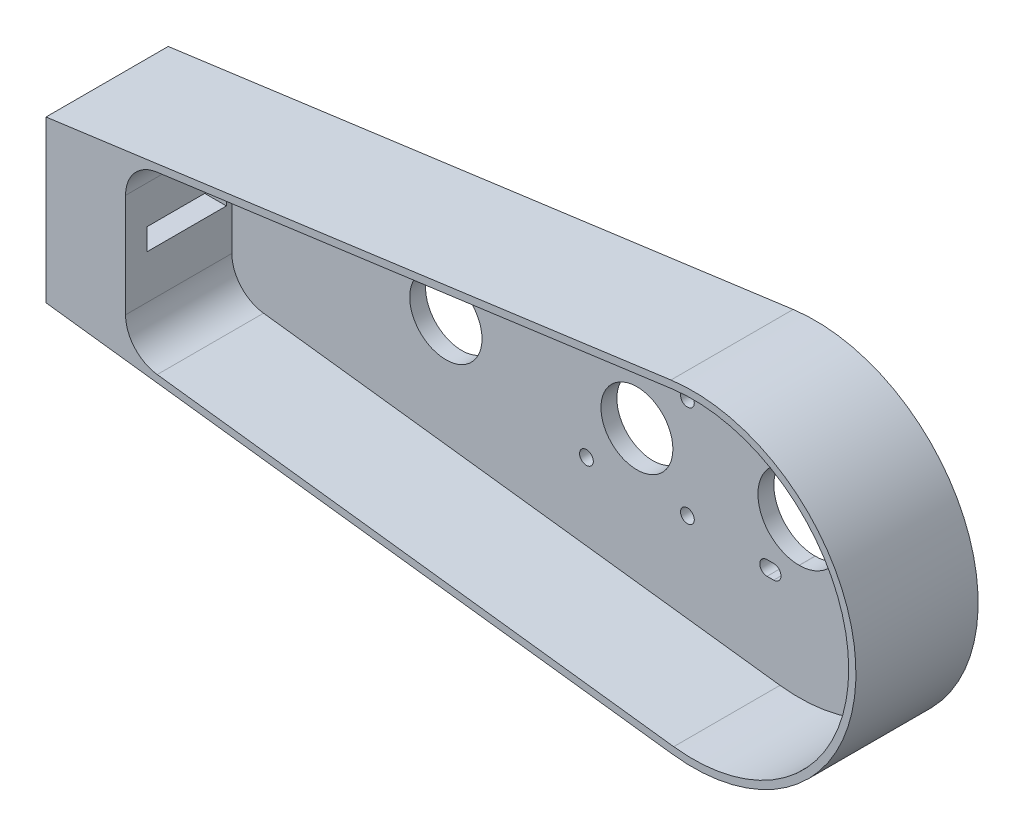
from build123d import *

# Parameters (mm, degrees)
ESBO_O1_R                  = 9.95
ESBO_O1_R_2                = 1.9
ESBO_O1_R_3                = 10
ESBO_O1_R_4                = 2.9
RESSALTO_EXTRUS_O1_DEPTH   = 30.8
ESBO_O1_3_R                = 9.95
ESBO_O1_3_R_2              = 1.9
ESBO_O1_3_R_3              = 10
ESBO_O1_3_R_4              = 2.9
RESSALTO_EXTRUS_O2_DEPTH   = 3
RESSALTO_EXTRUS_O4_DEPTH   = 33.8
CORTE_EXTRUS_O1_DEPTH      = 29.4
ESBO_O1_4_R                = 9.95
ESBO_O1_4_R_2              = 1.9
ESBO_O1_4_R_3              = 10
ESBO_O1_4_R_4              = 2.9
CORTE_EXTRUS_O2_DEPTH      = 31.8
CORTE_EXTRUS_O2_DEPTH_BACK = 4
RESSALTO_EXTRUS_O5_DEPTH   = 30.8
FILETE1_R                  = 10
CORTE_EXTRUS_O3_REACH      = 226.029
ESBO_O5_W                  = 22
ESBO_O5_H                  = 6


with BuildPart() as part:
    # Esboço1 → Ressalto-extrusão1 (new body)
    with BuildSketch(Plane.XY):
        with BuildLine():
            Line((-176.929134073, 19.50886441), (-176.929134073, -21.49113559))
            Line((-176.929134073, -21.49113559), (-5.303716409, -42.772427944))
            ThreePointArc((-5.303716409, -42.772427944), (43.09930295, 0.245122927), (-5.789885285, 42.709334207))
            Line((-5.789885285, 42.709334207), (-176.929134073, 19.50886441))
        make_face()
        with Locations((-44.879134073, -0.99113559)):
            Circle(ESBO_O1_R, mode=Mode.SUBTRACT)
        with Locations((-58.844493002, 12.974223338)):
            Circle(ESBO_O1_R_2, mode=Mode.SUBTRACT)
        with Locations((-97.729134073, -0.99113559)):
            Circle(ESBO_O1_R_3, mode=Mode.SUBTRACT)
        with Locations((-58.844493002, -14.956494518)):
            Circle(ESBO_O1_R_2, mode=Mode.SUBTRACT)
        with Locations((4, 24)):
            Circle(ESBO_O1_R_4, mode=Mode.SUBTRACT)
        with BuildLine():
            Line((22.160394843, 16.45886441), (24.010394843, 16.45886441))
            ThreePointArc((24.010394843, 16.45886441), (26.010394843, 14.45886441), (24.010394843, 12.45886441))
            Line((24.010394843, 12.45886441), (22.160394843, 12.45886441))
            ThreePointArc((22.160394843, 12.45886441), (20.160394843, 14.45886441), (22.160394843, 16.45886441))
        make_face(mode=Mode.SUBTRACT)
        with Locations((-30.913775145, -14.956494518)):
            Circle(ESBO_O1_R_2, mode=Mode.SUBTRACT)
        with BuildLine():
            Line((-7.039605157, -18.44113559), (-8.889605157, -18.44113559))
            ThreePointArc((-8.889605157, -18.44113559), (-10.889605157, -16.44113559), (-8.889605157, -14.44113559))
            Line((-8.889605157, -14.44113559), (-7.039605157, -14.44113559))
            ThreePointArc((-7.039605157, -14.44113559), (-5.039605157, -16.44113559), (-7.039605157, -18.44113559))
        make_face(mode=Mode.SUBTRACT)
        with BuildLine():
            Line((24.010394843, -18.44113559), (22.160394843, -18.44113559))
            ThreePointArc((22.160394843, -18.44113559), (20.160394843, -16.44113559), (22.160394843, -14.44113559))
            Line((22.160394843, -14.44113559), (24.010394843, -14.44113559))
            ThreePointArc((24.010394843, -14.44113559), (26.010394843, -16.44113559), (24.010394843, -18.44113559))
        make_face(mode=Mode.SUBTRACT)
        with Locations((-30.913775145, 12.974223338)):
            Circle(ESBO_O1_R_2, mode=Mode.SUBTRACT)
        with BuildLine():
            ThreePointArc((-0.025, -11.375), (-11.4, 0), (-0.025, 11.375))
            Line((-0.025, 11.375), (0.025, 11.375))
            ThreePointArc((0.025, 11.375), (11.4, 0), (0.025, -11.375))
            Line((0.025, -11.375), (-0.025, -11.375))
        make_face(mode=Mode.SUBTRACT)
        with BuildLine():
            ThreePointArc((-8.889605157, 12.45886441), (-10.889605157, 14.45886441), (-8.889605157, 16.45886441))
            Line((-8.889605157, 16.45886441), (-7.039605157, 16.45886441))
            ThreePointArc((-7.039605157, 16.45886441), (-5.039605157, 14.45886441), (-7.039605157, 12.45886441))
            Line((-7.039605157, 12.45886441), (-8.889605157, 12.45886441))
        make_face(mode=Mode.SUBTRACT)
    extrude(amount=RESSALTO_EXTRUS_O1_DEPTH)

    # Esboço1<3> → Ressalto-extrusão2 (add)
    with BuildSketch(Plane.XY):
        with BuildLine():
            Line((-176.929134073, 19.50886441), (-176.929134073, -21.49113559))
            Line((-176.929134073, -21.49113559), (-5.303716409, -42.772427944))
            ThreePointArc((-5.303716409, -42.772427944), (43.09930295, 0.245122927), (-5.789885285, 42.709334207))
            Line((-5.789885285, 42.709334207), (-176.929134073, 19.50886441))
        make_face()
        with Locations((-44.879134073, -0.99113559)):
            Circle(ESBO_O1_3_R, mode=Mode.SUBTRACT)
        with Locations((-58.844493002, 12.974223338)):
            Circle(ESBO_O1_3_R_2, mode=Mode.SUBTRACT)
        with Locations((-97.729134073, -0.99113559)):
            Circle(ESBO_O1_3_R_3, mode=Mode.SUBTRACT)
        with Locations((-58.844493002, -14.956494518)):
            Circle(ESBO_O1_3_R_2, mode=Mode.SUBTRACT)
        with Locations((4, 24)):
            Circle(ESBO_O1_3_R_4, mode=Mode.SUBTRACT)
        with BuildLine():
            Line((22.160394843, 16.45886441), (24.010394843, 16.45886441))
            ThreePointArc((24.010394843, 16.45886441), (26.010394843, 14.45886441), (24.010394843, 12.45886441))
            Line((24.010394843, 12.45886441), (22.160394843, 12.45886441))
            ThreePointArc((22.160394843, 12.45886441), (20.160394843, 14.45886441), (22.160394843, 16.45886441))
        make_face(mode=Mode.SUBTRACT)
        with Locations((-30.913775145, -14.956494518)):
            Circle(ESBO_O1_3_R_2, mode=Mode.SUBTRACT)
        with BuildLine():
            Line((-7.039605157, -18.44113559), (-8.889605157, -18.44113559))
            ThreePointArc((-8.889605157, -18.44113559), (-10.889605157, -16.44113559), (-8.889605157, -14.44113559))
            Line((-8.889605157, -14.44113559), (-7.039605157, -14.44113559))
            ThreePointArc((-7.039605157, -14.44113559), (-5.039605157, -16.44113559), (-7.039605157, -18.44113559))
        make_face(mode=Mode.SUBTRACT)
        with BuildLine():
            Line((24.010394843, -18.44113559), (22.160394843, -18.44113559))
            ThreePointArc((22.160394843, -18.44113559), (20.160394843, -16.44113559), (22.160394843, -14.44113559))
            Line((22.160394843, -14.44113559), (24.010394843, -14.44113559))
            ThreePointArc((24.010394843, -14.44113559), (26.010394843, -16.44113559), (24.010394843, -18.44113559))
        make_face(mode=Mode.SUBTRACT)
        with Locations((-30.913775145, 12.974223338)):
            Circle(ESBO_O1_3_R_2, mode=Mode.SUBTRACT)
        with BuildLine():
            ThreePointArc((-0.025, -11.375), (-11.4, 0), (-0.025, 11.375))
            Line((-0.025, 11.375), (0.025, 11.375))
            ThreePointArc((0.025, 11.375), (11.4, 0), (0.025, -11.375))
            Line((0.025, -11.375), (-0.025, -11.375))
        make_face(mode=Mode.SUBTRACT)
        with BuildLine():
            ThreePointArc((-8.889605157, 12.45886441), (-10.889605157, 14.45886441), (-8.889605157, 16.45886441))
            Line((-8.889605157, 16.45886441), (-7.039605157, 16.45886441))
            ThreePointArc((-7.039605157, 16.45886441), (-5.039605157, 14.45886441), (-7.039605157, 12.45886441))
            Line((-7.039605157, 12.45886441), (-8.889605157, 12.45886441))
        make_face(mode=Mode.SUBTRACT)
    extrude(amount=-RESSALTO_EXTRUS_O2_DEPTH)

    # Esboço4 → Ressalto-extrusão4 (add, through all)
    with BuildSketch(Plane(origin=(0, 0, -3), x_dir=(-1, 0, 0), z_dir=(0, 0, -1))):
        with BuildLine():
            Line((5.549828539, -44.757227385), (178.929134073, -23.258455586))
            Line((178.929134073, -23.258455586), (178.929134073, 21.256028837))
            Line((178.929134073, 21.256028837), (6.058557456, 44.691205864))
            ThreePointArc((6.058557456, 44.691205864), (-45.099270604, 0.25649754), (5.549828539, -44.757227385))
        make_face()
    extrude(amount=-RESSALTO_EXTRUS_O4_DEPTH)

    # Esboço2 → Corte-extrusão1 (cut)
    with BuildSketch(Plane.XY.offset(30.8)):
        with BuildLine():
            Line((-5.789885285, 42.709334207), (-176.929134073, 19.50886441))
            Line((-176.929134073, 19.50886441), (-176.929134073, -21.49113559))
            Line((-176.929134073, -21.49113559), (-5.303716409, -42.772427944))
            ThreePointArc((-5.303716409, -42.772427944), (43.09930295, 0.245122927), (-5.789885285, 42.709334207))
        make_face()
    extrude(amount=-CORTE_EXTRUS_O1_DEPTH, mode=Mode.SUBTRACT)

    # Esboço1<4> → Corte-extrusão2 (cut, two sides)
    with BuildSketch(Plane.XY) as corte_extrus_o2_sk:
        with Locations((-44.879134073, -0.99113559)):
            Circle(ESBO_O1_4_R)
        with Locations((-30.913775145, 12.974223338)):
            Circle(ESBO_O1_4_R_2)
        with Locations((-58.844493002, -14.956494518)):
            Circle(ESBO_O1_4_R_2)
        with Locations((-30.913775145, -14.956494518)):
            Circle(ESBO_O1_4_R_2)
        with Locations((-58.844493002, 12.974223338)):
            Circle(ESBO_O1_4_R_2)
        with Locations((-97.729134073, -0.99113559)):
            Circle(ESBO_O1_4_R_3)
        with Locations((4, 24)):
            Circle(ESBO_O1_4_R_4)
        with BuildLine():
            Line((-0.025, 11.375), (0.025, 11.375))
            ThreePointArc((0.025, 11.375), (11.4, 0), (0.025, -11.375))
            Line((0.025, -11.375), (-0.025, -11.375))
            ThreePointArc((-0.025, -11.375), (-11.4, 0), (-0.025, 11.375))
        make_face()
        with BuildLine():
            Line((22.160394843, 16.45886441), (24.010394843, 16.45886441))
            ThreePointArc((24.010394843, 16.45886441), (26.010394843, 14.45886441), (24.010394843, 12.45886441))
            Line((24.010394843, 12.45886441), (22.160394843, 12.45886441))
            ThreePointArc((22.160394843, 12.45886441), (20.160394843, 14.45886441), (22.160394843, 16.45886441))
        make_face()
        with BuildLine():
            Line((-8.889605157, 16.45886441), (-7.039605157, 16.45886441))
            ThreePointArc((-7.039605157, 16.45886441), (-5.039605157, 14.45886441), (-7.039605157, 12.45886441))
            Line((-7.039605157, 12.45886441), (-8.889605157, 12.45886441))
            ThreePointArc((-8.889605157, 12.45886441), (-10.889605157, 14.45886441), (-8.889605157, 16.45886441))
        make_face()
        with BuildLine():
            Line((22.160394843, -18.44113559), (24.010394843, -18.44113559))
            ThreePointArc((24.010394843, -18.44113559), (26.010394843, -16.44113559), (24.010394843, -14.44113559))
            Line((24.010394843, -14.44113559), (22.160394843, -14.44113559))
            ThreePointArc((22.160394843, -14.44113559), (20.160394843, -16.44113559), (22.160394843, -18.44113559))
        make_face()
        with BuildLine():
            Line((-8.889605157, -18.44113559), (-7.039605157, -18.44113559))
            ThreePointArc((-7.039605157, -18.44113559), (-5.039605157, -16.44113559), (-7.039605157, -14.44113559))
            Line((-7.039605157, -14.44113559), (-8.889605157, -14.44113559))
            ThreePointArc((-8.889605157, -14.44113559), (-10.889605157, -16.44113559), (-8.889605157, -18.44113559))
        make_face()
    extrude(amount=CORTE_EXTRUS_O2_DEPTH, mode=Mode.SUBTRACT)
    extrude(corte_extrus_o2_sk.sketch, amount=-CORTE_EXTRUS_O2_DEPTH_BACK, mode=Mode.SUBTRACT)

    # Esboço1<5> → Ressalto-extrusão5 (add, through all)
    with BuildSketch(Plane.XY):
        Polygon((-156.929134073, 22.220161785), (-176.929134073, 19.50886441), (-176.929134073, -21.49113559), (-156.929134073, -23.971105357), align=None)
    extrude(amount=RESSALTO_EXTRUS_O5_DEPTH)

    # Filete1
    filete1_edges = [part.edges().sort_by_distance(p)[0] for p in [
        (-156.929134073, -23.971105357, 16.1),
        (-156.929134073, 22.220161785, 16.1),
    ]]
    fillet(filete1_edges, radius=FILETE1_R)

    # Esboço5 → Corte-extrusão3 (cut, up to next)
    with BuildSketch(Plane.ZY.offset(178.929134073), mode=Mode.PRIVATE) as corte_extrus_o3_sk1:
        with Locations((13.9, 0)):
            Rectangle(ESBO_O5_W, ESBO_O5_H)
    corte_extrus_o3_tool1 = extrude(corte_extrus_o3_sk1.sketch, amount=-CORTE_EXTRUS_O3_REACH, mode=Mode.PRIVATE) & part.part
    add(corte_extrus_o3_tool1.solids().sort_by_distance((-178.929134, 0, 13.9))[0], mode=Mode.SUBTRACT)


solid = part.part
